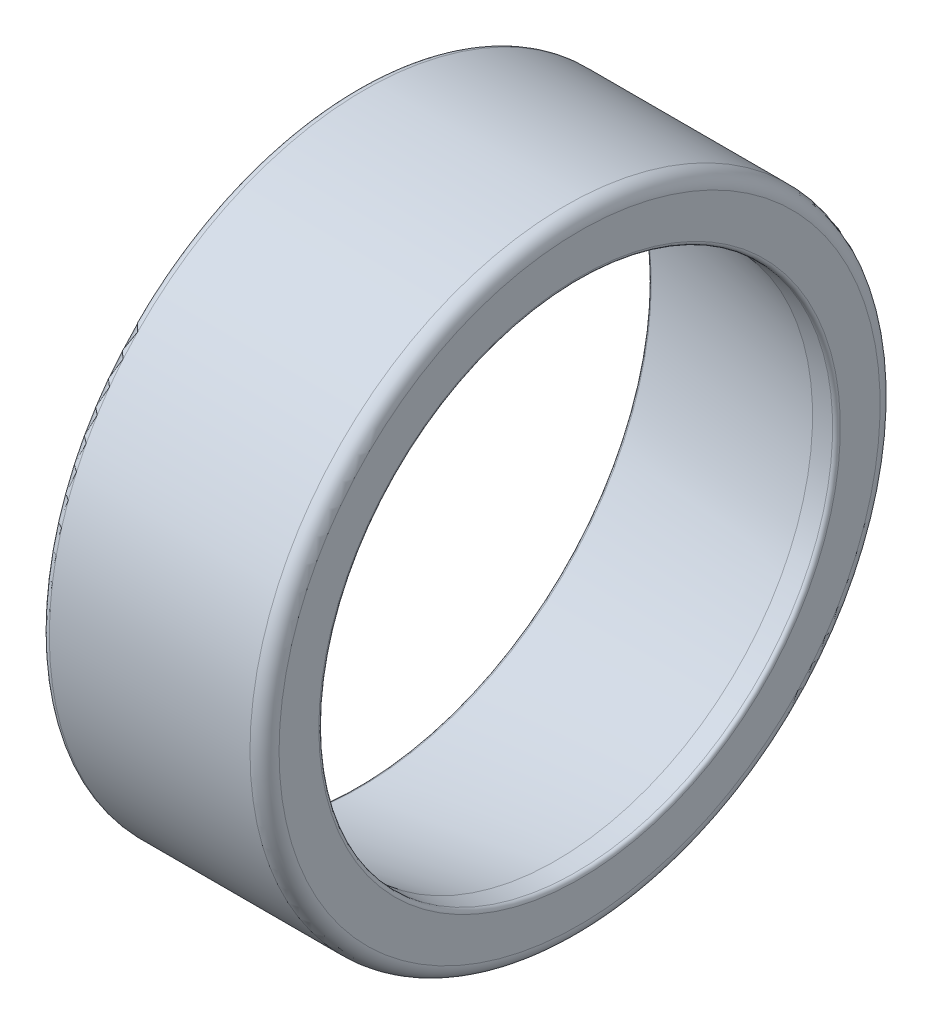
from build123d import *

# Parameters (mm, degrees)
FILLET1_R = 1.5
FILLET2_R = 0.8
FILLET3_R = 0.4


with BuildPart() as part:
    # Sketch1 → Revolve1 (revolve)
    with BuildSketch(Plane.XY):
        Polygon((22, 26.5), (22, 32.5), (-1, 32.5), (-1, 30.120326542), (19.5318921, 26.5), align=None)
    revolve(axis=Axis((0, 0, 0), (1, 0, 0)))

    # Fillet1
    fillet1_edges = [part.edges().sort_by_distance(p)[0] for p in [
        (22, -32.5, 0),
    ]]
    fillet(fillet1_edges, radius=FILLET1_R)

    # Fillet2
    fillet2_edges = [part.edges().sort_by_distance(p)[0] for p in [
        (-1, -32.5, 0),
    ]]
    fillet(fillet2_edges, radius=FILLET2_R)

    # Fillet3
    fillet3_edges = [part.edges().sort_by_distance(p)[0] for p in [
        (22, -26.5, 0),
        (-1, -30.120326542, 0),
    ]]
    fillet(fillet3_edges, radius=FILLET3_R)


solid = part.part
